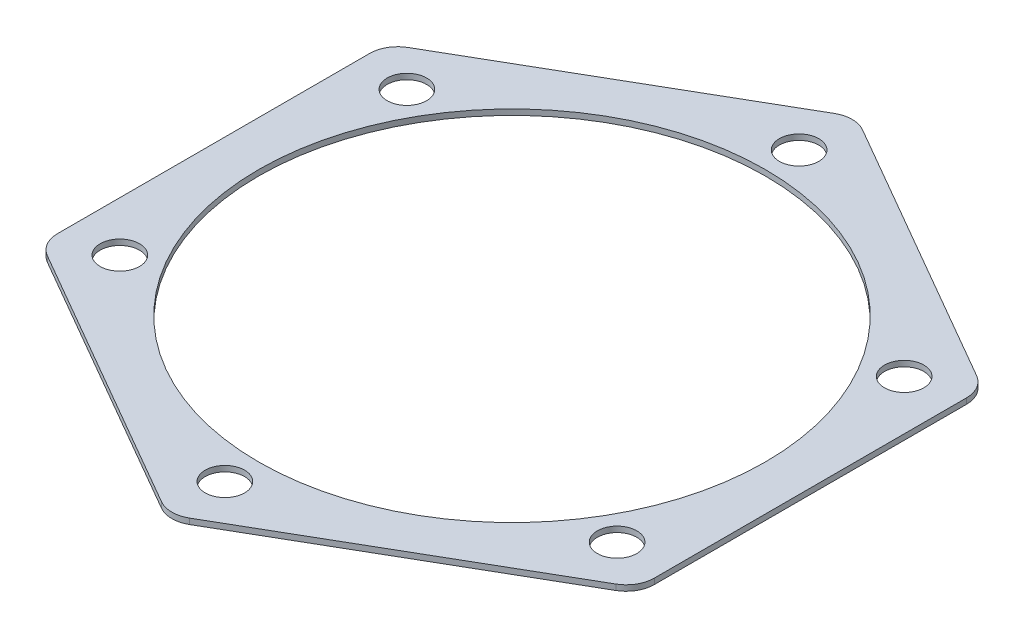
from build123d import *

# Parameters (mm, degrees)
SKETCH2_R           = 45
BOSS_EXTRUDE1_DEPTH = 1
SKETCH3_R           = 3.5
CUT_EXTRUDE1_DEPTH  = 1
CIRPATTERN1_COUNT   = 6


with BuildPart() as part:
    # Sketch2 → Boss-Extrude1 (new body)
    with BuildSketch(Plane(origin=(0, 0, 0), x_dir=(1, 0, 0), z_dir=(0, 1, 0))):
        with BuildLine():
            Line((-2.5, 59.755752861), (-50.5, 32.04293994))
            ThreePointArc((-50.5, 32.04293994), (-52.330127019, 30.212812921), (-53, 27.712812921))
            Line((-53, 27.712812921), (-53, -27.712812921))
            ThreePointArc((-53, -27.712812921), (-52.330127019, -30.212812921), (-50.5, -32.04293994))
            Line((-50.5, -32.04293994), (-2.5, -59.755752861))
            ThreePointArc((-2.5, -59.755752861), (0, -60.425625842), (2.5, -59.755752861))
            Line((2.5, -59.755752861), (50.5, -32.04293994))
            ThreePointArc((50.5, -32.04293994), (52.330127019, -30.212812921), (53, -27.712812921))
            Line((53, -27.712812921), (53, 27.712812921))
            ThreePointArc((53, 27.712812921), (52.330127019, 30.212812921), (50.5, 32.04293994))
            Line((50.5, 32.04293994), (2.5, 59.755752861))
            ThreePointArc((2.5, 59.755752861), (0, 60.425625842), (-2.5, 59.755752861))
        make_face()
        Circle(SKETCH2_R, mode=Mode.SUBTRACT)
    extrude(amount=BOSS_EXTRUDE1_DEPTH)

    # Sketch3 → Cut-Extrude1 (cut)
    with BuildSketch(Plane(origin=(0, 1, 0), x_dir=(1, 0, 0), z_dir=(0, 1, 0))):
        with Locations((0, 51)):
            Circle(SKETCH3_R)
    cut_extrude1 = extrude(amount=-CUT_EXTRUDE1_DEPTH, mode=Mode.SUBTRACT)

    # CirPattern1: Cut-Extrude1 ×6 about axis
    cirpattern1_axis = Axis((0, 0, 0), (0, 1, 0))
    for i in range(1, CIRPATTERN1_COUNT):
        add(cut_extrude1.rotate(cirpattern1_axis, i * 360 / CIRPATTERN1_COUNT), mode=Mode.SUBTRACT)


solid = part.part
